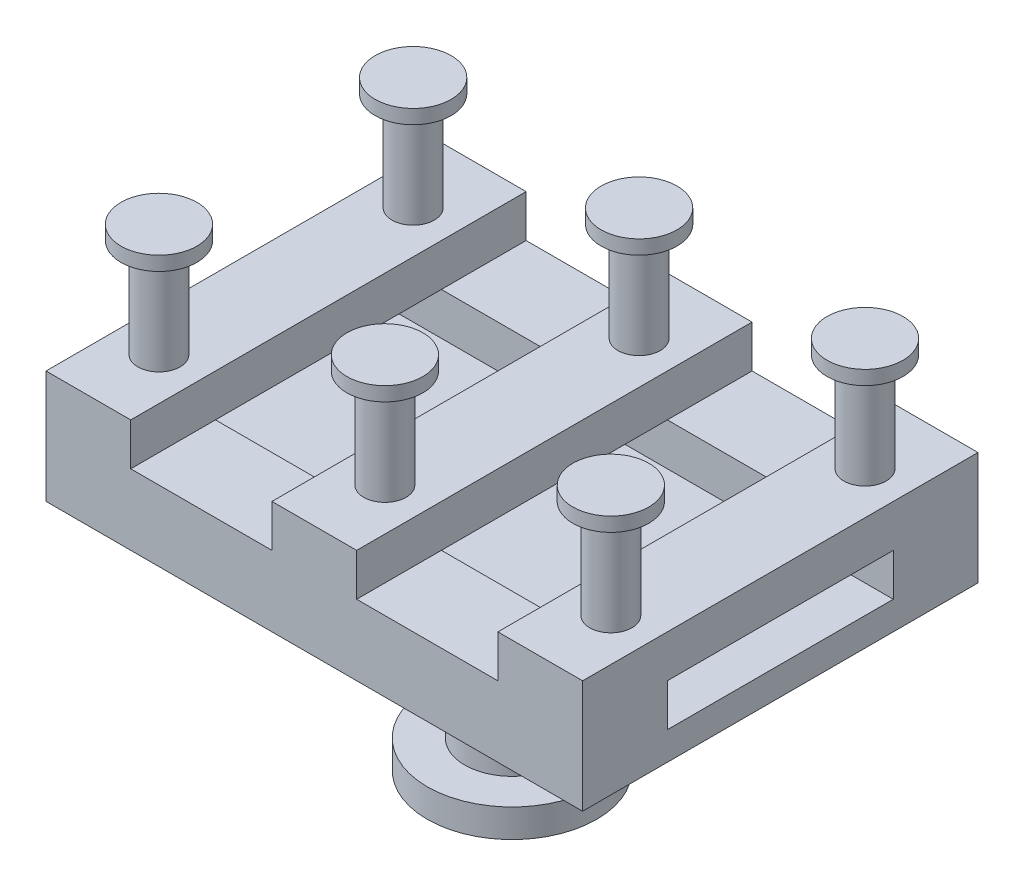
from build123d import *

# Parameters (mm, degrees)
SKETCH_3_R      = 60
EXTRUDE_1_DEPTH = 20
SKETCH_4_R      = 33.420656991
EXTRUDE_2_DEPTH = 110
SKETCH_7_R      = 60
EXTRUDE_4_DEPTH = 10
SKETCH_9_W      = 380
SKETCH_9_H      = 280
EXTRUDE_5_DEPTH = 20
SKETCH_11_W     = 380
SKETCH_11_H     = 60
EXTRUDE_6_DEPTH = 30
SKETCH_13_W     = 60
SKETCH_13_H     = 30
EXTRUDE_7_DEPTH = 280
SKETCH_14_R     = 15
EXTRUDE_8_DEPTH = 70
SKETCH_16_R     = 26.879561929
EXTRUDE_9_DEPTH = 10


with BuildPart() as part:
    # 草图3 → 凸台-拉伸1 (new body)
    with BuildSketch(Plane(origin=(0, 0, 0), x_dir=(1, 0, 0), z_dir=(0, 1, 0))):
        Circle(SKETCH_3_R)
    extrude(amount=EXTRUDE_1_DEPTH)

    # 草图4 → 凸台-拉伸2 (add)
    with BuildSketch(Plane(origin=(0, 20, 0), x_dir=(1, 0, 0), z_dir=(0, 1, 0))):
        Circle(SKETCH_4_R)
    extrude(amount=EXTRUDE_2_DEPTH)

    # 草图7 → 凸台-拉伸4 (add)
    with BuildSketch(Plane(origin=(0, 130, 0), x_dir=(1, 0, 0), z_dir=(0, 1, 0))):
        Circle(SKETCH_7_R)
    extrude(amount=EXTRUDE_4_DEPTH)

    # 草图9 → 凸台-拉伸5 (add)
    with BuildSketch(Plane(origin=(0, 140, 0), x_dir=(1, 0, 0), z_dir=(0, 1, 0))):
        Rectangle(SKETCH_9_W, SKETCH_9_H)
    extrude(amount=EXTRUDE_5_DEPTH)

    # 草图11 → 凸台-拉伸6 (add)
    with BuildSketch(Plane(origin=(0, 160, 0), x_dir=(1, 0, 0), z_dir=(0, 1, 0))):
        with Locations((0, 110)):
            Rectangle(SKETCH_11_W, SKETCH_11_H)
        with Locations((0, -110)):
            Rectangle(SKETCH_11_W, SKETCH_11_H)
    extrude(amount=EXTRUDE_6_DEPTH)

    # 草图13 → 凸台-拉伸7 (add)
    with BuildSketch(Plane.XY.offset(140)):
        with Locations((-160, 205)):
            Rectangle(SKETCH_13_W, SKETCH_13_H)
        with Locations((0, 205)):
            Rectangle(SKETCH_13_W, SKETCH_13_H)
        with Locations((160, 205)):
            Rectangle(SKETCH_13_W, SKETCH_13_H)
    extrude(amount=-EXTRUDE_7_DEPTH)

    # 草图14 → 凸台-拉伸8 (add)
    with BuildSketch(Plane(origin=(0, 220, 0), x_dir=(1, 0, 0), z_dir=(0, 1, 0))):
        with Locations((-160, 90)):
            Circle(SKETCH_14_R)
        with Locations((0, 90)):
            Circle(SKETCH_14_R)
        with Locations((160, 90)):
            Circle(SKETCH_14_R)
        with Locations((-160, -90)):
            Circle(SKETCH_14_R)
        with Locations((0, -90)):
            Circle(SKETCH_14_R)
        with Locations((160, -90)):
            Circle(SKETCH_14_R)
    extrude(amount=EXTRUDE_8_DEPTH)

    # 草图16 → 凸台-拉伸9 (add)
    with BuildSketch(Plane(origin=(0, 290, 0), x_dir=(1, 0, 0), z_dir=(0, 1, 0))):
        with Locations((-160, 90)):
            Circle(SKETCH_16_R)
        with Locations((0, 90)):
            Circle(SKETCH_16_R)
        with Locations((160, 90)):
            Circle(SKETCH_16_R)
        with Locations((-160, -90)):
            Circle(SKETCH_16_R)
        with Locations((0, -90)):
            Circle(SKETCH_16_R)
        with Locations((160, -90)):
            Circle(SKETCH_16_R)
    extrude(amount=EXTRUDE_9_DEPTH)


solid = part.part
